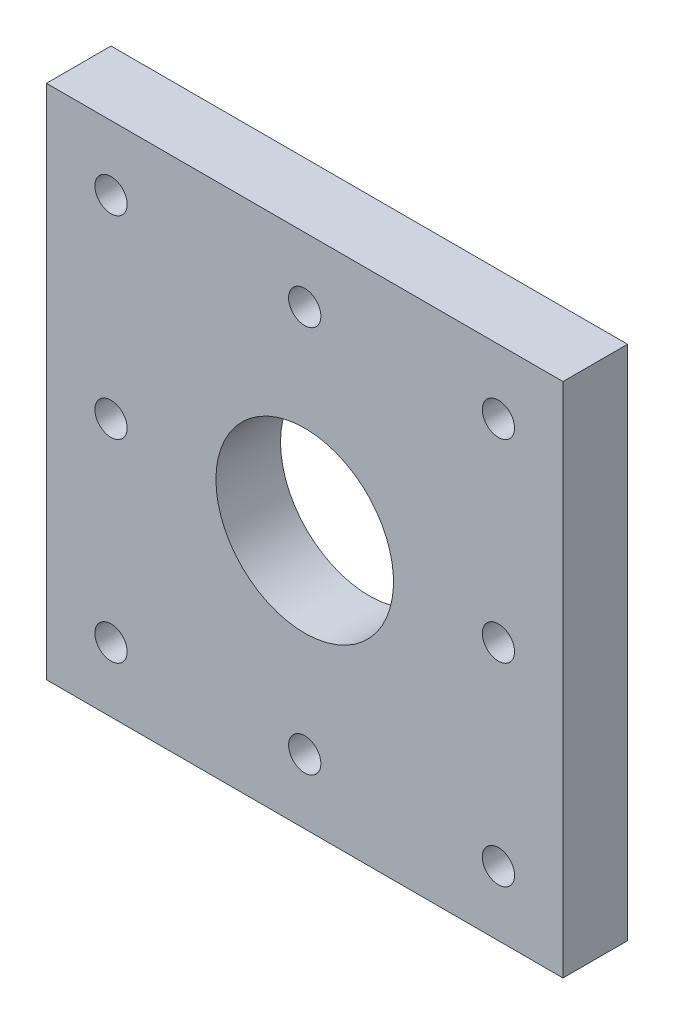
from build123d import *

# Parameters (mm, degrees)
SKETCH1_W           = 50.8
SKETCH1_H           = 50.8
BOSS_EXTRUDE1_DEPTH = 6.35
SKETCH2_R           = 8.73125
CUT_EXTRUDE7_DEPTH  = 7.35
SKETCH5_R           = 1.5875
CUT_EXTRUDE8_DEPTH  = 7.35
SKETCH7_R           = 1.5875
CUT_EXTRUDE9_DEPTH  = 7.35


with BuildPart() as part:
    # Sketch1 → Boss-Extrude1 (new body)
    with BuildSketch(Plane.XY):
        with Locations((25.4, 25.4)):
            Rectangle(SKETCH1_W, SKETCH1_H)
    extrude(amount=BOSS_EXTRUDE1_DEPTH)

    # Sketch2 → Cut-Extrude7 (cut, through all)
    with BuildSketch(Plane(origin=(0, 0, 0), x_dir=(-1, 0, 0), z_dir=(0, 0, -1))):
        with Locations((-25.4, 25.4)):
            Circle(SKETCH2_R)
    extrude(amount=-CUT_EXTRUDE7_DEPTH, mode=Mode.SUBTRACT)

    # Sketch5 → Cut-Extrude8 (cut, through all)
    with BuildSketch(Plane.XY.offset(6.35)):
        with Locations((25.4, 6.35)):
            Circle(SKETCH5_R)
        with Locations((6.35, 25.4)):
            Circle(SKETCH5_R)
        with Locations((25.4, 44.45)):
            Circle(SKETCH5_R)
        with Locations((44.45, 25.4)):
            Circle(SKETCH5_R)
    extrude(amount=-CUT_EXTRUDE8_DEPTH, mode=Mode.SUBTRACT)

    # Sketch7 → Cut-Extrude9 (cut, through all)
    with BuildSketch(Plane(origin=(0, 0, 0), x_dir=(-1, 0, 0), z_dir=(0, 0, -1))):
        with Locations((-6.35, 6.35)):
            Circle(SKETCH7_R)
        with Locations((-44.45, 6.35)):
            Circle(SKETCH7_R)
        with Locations((-44.45, 44.45)):
            Circle(SKETCH7_R)
        with Locations((-6.35, 44.45)):
            Circle(SKETCH7_R)
    extrude(amount=-CUT_EXTRUDE9_DEPTH, mode=Mode.SUBTRACT)


solid = part.part
